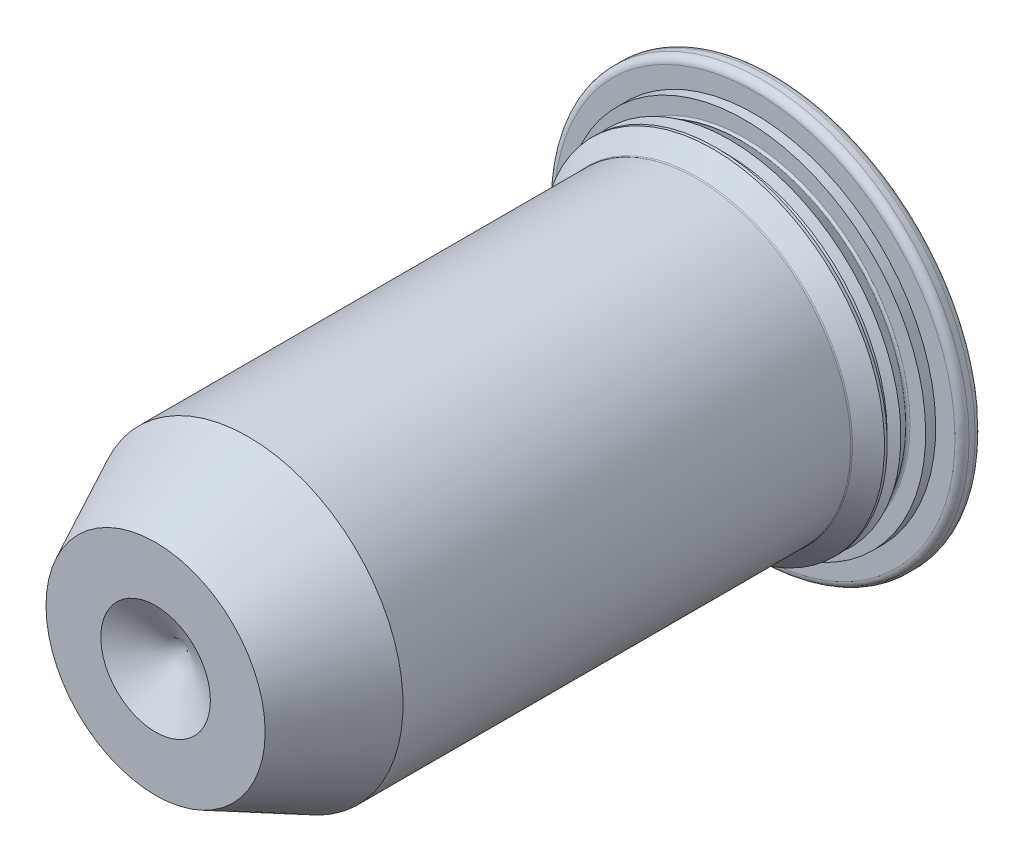
from build123d import *

# Parameters (mm, degrees)
FILLET1_R = 0.0381


with BuildPart() as part:
    # Sketch2 → Revolve1 (revolve)
    with BuildSketch(Plane(origin=(0, 0, 0), x_dir=(0, 0, -1), z_dir=(1, 0, 0))):
        with BuildLine():
            Line((-6.35, 0), (6.35, 0))
            Line((6.35, 0), (6.35, 4.1105))
            ThreePointArc((6.35, 4.1105), (6.307823376, 4.212323376), (6.206, 4.2545))
            Line((6.206, 4.2545), (6.082012, 4.2545))
            ThreePointArc((6.082012, 4.2545), (5.980188624, 4.212323376), (5.938012, 4.1105))
            Line((5.938012, 4.1105), (5.938012, 3.71475))
            Line((5.938012, 3.71475), (5.732012, 3.71475))
            Line((5.732012, 3.71475), (5.732012, 3.513963))
            Line((5.732012, 3.513963), (5.425012, 3.513963))
            Line((5.425012, 3.513963), (5.3309875, 3.32591358))
            ThreePointArc((5.3309875, 3.32591358), (5.2849875, 3.313587917), (5.2389875, 3.32591358))
            Line((5.2389875, 3.32591358), (5.144963, 3.513963))
            Line((5.144963, 3.513963), (5.088963, 3.513963))
            Line((5.088963, 3.513963), (4.75, 3.175))
            Line((4.75, 3.175), (-4.449163308, 3.175))
            Line((-4.449163308, 3.175), (-6.35, 2.2479))
            Line((-6.35, 2.2479), (-6.35, 0))
        make_face()
    revolve(axis=Axis((0, 0, 6.35), (0, 0, -1)))

    # Sketch3 → Cut-Revolve1 (revolve, cut)
    with BuildSketch(Plane(origin=(0, 0, 0), x_dir=(0, 0, -1), z_dir=(1, 0, 0))):
        Polygon((-6.35, 1.12395), (-5.701087165, 0), (-6.35, 0), align=None)
    revolve(axis=Axis((0, 0, 6.35), (0, 0, -1)), mode=Mode.SUBTRACT)

    # Sketch4 → Cut-Revolve2 (revolve, cut)
    with BuildSketch(Plane(origin=(0, 0, 0), x_dir=(0, 0, -1), z_dir=(1, 0, 0))):
        Polygon((5.425012, 3.513963), (5.732012, 3.32591358), (5.732012, 3.513963), align=None)
    revolve(axis=Axis((0, 0, 6.35), (0, 0, -1)), mode=Mode.SUBTRACT)

    # Fillet1
    fillet1_edges = [part.edges().sort_by_distance(p)[0] for p in [
        (0, -3.175, -4.75),
        (0, -3.32591358, -5.732012),
    ]]
    fillet(fillet1_edges, radius=FILLET1_R)


solid = part.part
